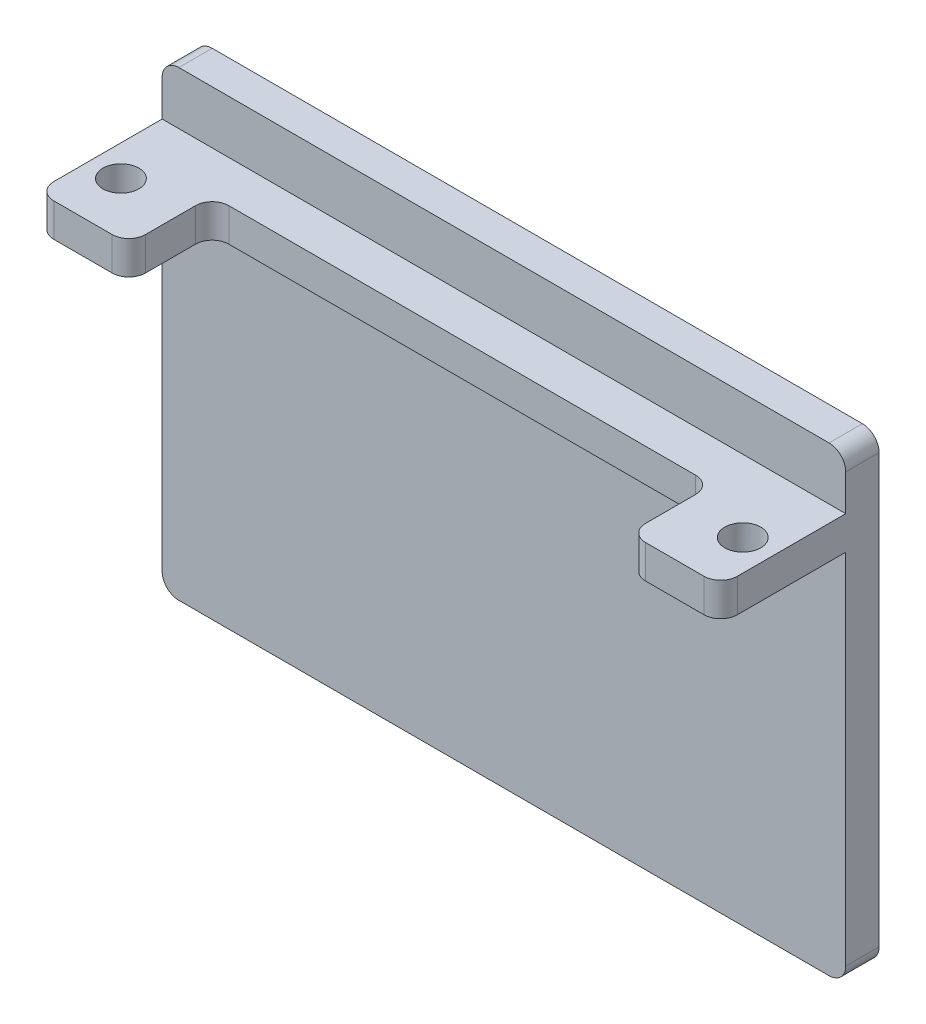
from build123d import *

# Parameters (mm, degrees)
SKETCH1_W           = 82
SKETCH1_H           = 49
BOSS_EXTRUDE1_DEPTH = 4
SKETCH2_W           = 82
SKETCH2_H           = 4
BOSS_EXTRUDE2_DEPTH = 15
SKETCH3_R           = 2.159
CUT_EXTRUDE1_DEPTH  = 50
SKETCH4_W           = 82
SKETCH4_H           = 4
BOSS_EXTRUDE3_DEPTH = 6.35
SKETCH5_W           = 60
SKETCH5_H           = 4
CUT_EXTRUDE2_DEPTH  = 10
FILLET1_R           = 2


with BuildPart() as part:
    # Sketch1 → Boss-Extrude1 (new body)
    with BuildSketch(Plane.XY):
        with Locations((41, -24.5)):
            Rectangle(SKETCH1_W, SKETCH1_H)
    extrude(amount=BOSS_EXTRUDE1_DEPTH)

    # Sketch2 → Boss-Extrude2 (add)
    with BuildSketch(Plane.XY.offset(4)):
        with Locations((41, -2)):
            Rectangle(SKETCH2_W, SKETCH2_H)
    extrude(amount=BOSS_EXTRUDE2_DEPTH)

    # Sketch3 → Cut-Extrude1 (cut, through all)
    with BuildSketch(Plane(origin=(0, 0, 0), x_dir=(1, 0, 0), z_dir=(0, 1, 0))):
        with Locations((3.704833995, -12.65)):
            Circle(SKETCH3_R)
        with Locations((78.295166005, -12.65)):
            Circle(SKETCH3_R)
    extrude(amount=-CUT_EXTRUDE1_DEPTH, mode=Mode.SUBTRACT)

    # Sketch4 → Boss-Extrude3 (add)
    with BuildSketch(Plane(origin=(0, 0, 0), x_dir=(1, 0, 0), z_dir=(0, 1, 0))):
        with Locations((41, -2)):
            Rectangle(SKETCH4_W, SKETCH4_H)
    extrude(amount=BOSS_EXTRUDE3_DEPTH)

    # Sketch5 → Cut-Extrude2 (cut)
    with BuildSketch(Plane.XY.offset(19)):
        with Locations((41, -2)):
            Rectangle(SKETCH5_W, SKETCH5_H)
    extrude(amount=-CUT_EXTRUDE2_DEPTH, mode=Mode.SUBTRACT)

    # Fillet1
    fillet1_edges = [part.edges().sort_by_distance(p)[0] for p in [
        (0, -2, 19),
        (82, -2, 19),
        (0, 6.35, 2),
        (82, 6.35, 2),
        (71, -2, 9),
        (11, -2, 9),
        (71, -2, 19),
        (11, -2, 19),
        (82, -49, 2),
        (0, -49, 2),
    ]]
    fillet(fillet1_edges, radius=FILLET1_R)


solid = part.part
